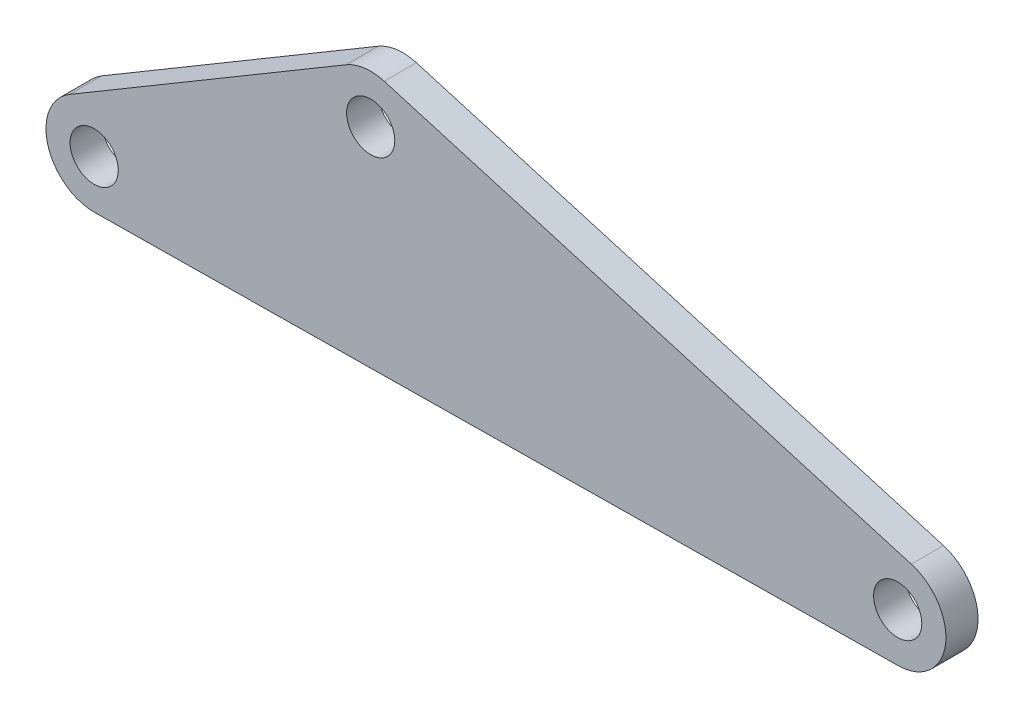
from build123d import *

# Parameters (mm, degrees)
SKETCH2_R           = 7.5
BOSS_EXTRUDE1_DEPTH = 10
FILLET1_R           = 15
FILLET2_R           = 15
FILLET3_R           = 15


with BuildPart() as part:
    # Sketch2 → Boss-Extrude1 (new body)
    with BuildSketch(Plane.XY):
        Polygon((-188.967985521, -4.587781845), (-49.180964379, 78.282699744), (217.267895037, 0.098297427), align=None)
        with Locations((-133.163966534, 11.056935849)):
            Circle(SKETCH2_R, mode=Mode.SUBTRACT)
        with Locations((-47.143917344, 62.052535044)):
            Circle(SKETCH2_R, mode=Mode.SUBTRACT)
        with Locations((116.819402044, 13.94058532)):
            Circle(SKETCH2_R, mode=Mode.SUBTRACT)
    extrude(amount=BOSS_EXTRUDE1_DEPTH)

    # Fillet1
    fillet1_edges = [part.edges().sort_by_distance(p)[0] for p in [
        (217.267895037, 0.098297427, 5),
    ]]
    fillet(fillet1_edges, radius=FILLET1_R)

    # Fillet2
    fillet2_edges = [part.edges().sort_by_distance(p)[0] for p in [
        (-49.180964379, 78.282699744, 5),
    ]]
    fillet(fillet2_edges, radius=FILLET2_R)

    # Fillet3
    fillet3_edges = [part.edges().sort_by_distance(p)[0] for p in [
        (-188.967985521, -4.587781845, 5),
    ]]
    fillet(fillet3_edges, radius=FILLET3_R)


solid = part.part
